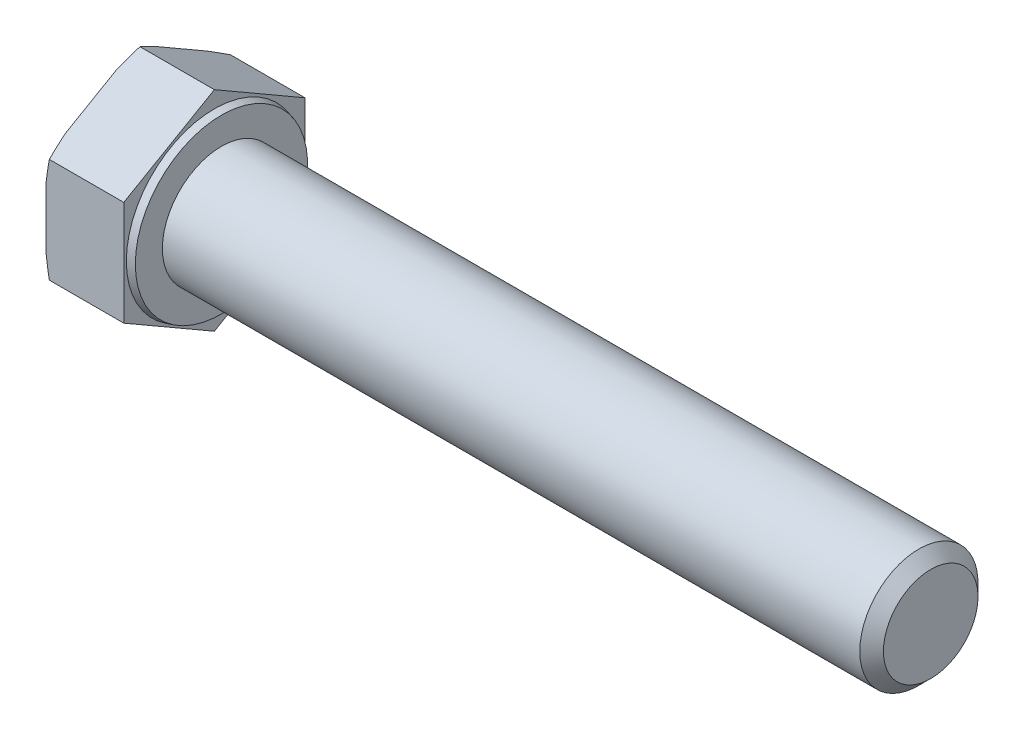
from build123d import *

# Parameters (mm, degrees)
SKETCH_2_OUTSIDE_W  = 34.038
SKETCH_2_OUTSIDE_H  = 34.038
CUT_EXTRUDE_1_DEPTH = 69.335915886
CHAMFER_1_SIZE      = 1


with BuildPart() as part:
    # Эскиз1 → Повернуть1 (revolve)
    with BuildSketch(Plane.XY, mode=Mode.PRIVATE) as revolve_1_sk:
        Polygon((-6.58, 0), (-6.58, 8.85), (0, 8.85), (0, 7.448974596), (0.6, 7.288205081), (0.6, 5), (60.6, 5), (60.6, 0), align=None)
    revolve(revolve_1_sk.sketch.rotate(Axis((-1000, 0, 0), (1, 0, 0)), 90), axis=Axis((-1000, 0, 0), (1, 0, 0)))

    # Эскиз2 outside → Вырез-Вытянуть1 (cut, through all)
    with BuildSketch(Plane.ZY.offset(6.58)):
        Rectangle(SKETCH_2_OUTSIDE_W, SKETCH_2_OUTSIDE_H)
        Polygon((0, -8.85), (7.664324823, -4.425), (7.664324823, 4.425), (0, 8.85), (-7.664324823, 4.425), (-7.664324823, -4.425), align=None, mode=Mode.SUBTRACT)
    extrude(amount=-CUT_EXTRUDE_1_DEPTH, mode=Mode.SUBTRACT)

    # Эскиз4 → Вырез-Повернуть1 (revolve, cut)
    with BuildSketch(Plane.XY):
        Polygon((-6.58, 8.075), (-6.297923068, 8.85), (-6.58, 8.85), align=None)
    revolve(axis=Axis((-1000, 0, 0), (1, 0, 0)), mode=Mode.SUBTRACT)

    # Фаска1
    chamfer_1_edges = [part.edges().sort_by_distance(p)[0] for p in [
        (60.6, 0, -5),
    ]]
    chamfer(chamfer_1_edges, length=CHAMFER_1_SIZE)


solid = part.part
